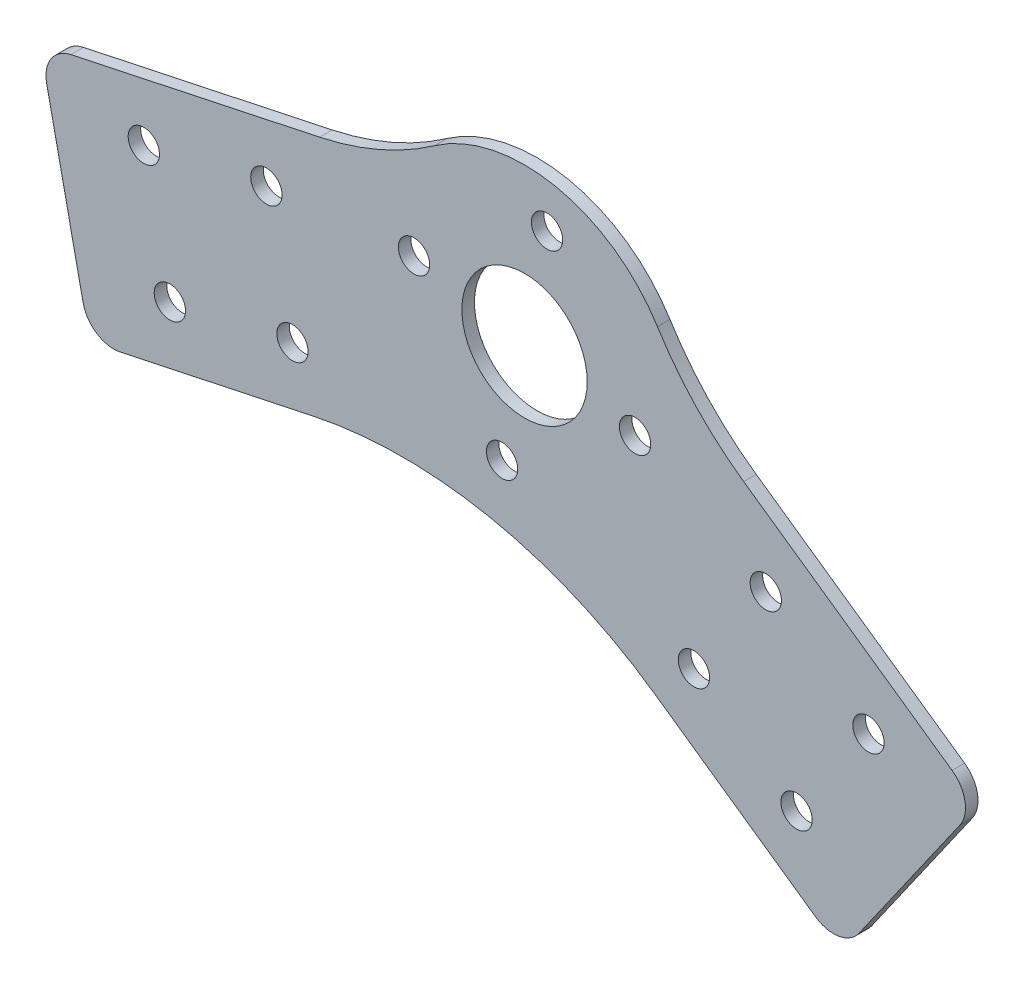
from build123d import *

# Parameters (mm, degrees)
SKETCH1_R           = 2.5
SKETCH1_R_2         = 10
BOSS_EXTRUDE1_DEPTH = 2
FILLET1_R           = 50
FILLET2_R           = 70
FILLET3_R           = 5


with BuildPart() as part:
    # Sketch1 → Boss-Extrude1 (new body)
    with BuildSketch(Plane.XY):
        with BuildLine():
            Line((-77.311392181, 2.991427603), (-69.410747929, -34.178181225))
            Line((-69.410747929, -34.178181225), (-4.13058082, -20.302453359))
            Line((-4.13058082, -20.302453359), (50.538451031, -58.582121568))
            Line((50.538451031, -58.582121568), (72.334355612, -27.454343885))
            Line((72.334355612, -27.454343885), (24.207597625, 6.244374848))
            ThreePointArc((24.207597625, 6.244374848), (4.98419836, 24.498117616), (-19.843339473, 15.206639292))
            Line((-19.843339473, 15.206639292), (-77.311392181, 2.991427603))
        make_face()
        with Locations((-60.767972952, -2.693225442)):
            Circle(SKETCH1_R, mode=Mode.SUBTRACT)
        with Locations((-56.609739136, -22.256177456)):
            Circle(SKETCH1_R, mode=Mode.SUBTRACT)
        with Locations((-37.046787121, -18.09794364)):
            Circle(SKETCH1_R, mode=Mode.SUBTRACT)
        with Locations((-41.205020938, 1.465008375)):
            Circle(SKETCH1_R, mode=Mode.SUBTRACT)
        with Locations((38.501846135, -14.751537011)):
            Circle(SKETCH1_R, mode=Mode.SUBTRACT)
        with Locations((27.030317408, -31.134577897)):
            Circle(SKETCH1_R, mode=Mode.SUBTRACT)
        with Locations((43.413358294, -42.606106624)):
            Circle(SKETCH1_R, mode=Mode.SUBTRACT)
        with Locations((54.884887021, -26.223065738)):
            Circle(SKETCH1_R, mode=Mode.SUBTRACT)
        Circle(SKETCH1_R_2, mode=Mode.SUBTRACT)
        with Locations((3.58862282, 17.638644683)):
            Circle(SKETCH1_R, mode=Mode.SUBTRACT)
        with Locations((17.638644683, -3.58862282)):
            Circle(SKETCH1_R, mode=Mode.SUBTRACT)
        with Locations((-3.58862282, -17.638644683)):
            Circle(SKETCH1_R, mode=Mode.SUBTRACT)
        with Locations((-17.638644683, 3.58862282)):
            Circle(SKETCH1_R, mode=Mode.SUBTRACT)
    extrude(amount=BOSS_EXTRUDE1_DEPTH)

    # Fillet1
    fillet1_edges = [part.edges().sort_by_distance(p)[0] for p in [
        (-19.843339473, 15.206639292, 1),
        (24.207597625, 6.244374848, 1),
    ]]
    fillet(fillet1_edges, radius=FILLET1_R)

    # Fillet2
    fillet2_edges = [part.edges().sort_by_distance(p)[0] for p in [
        (-4.13058082, -20.302453359, 1),
    ]]
    fillet(fillet2_edges, radius=FILLET2_R)

    # Fillet3
    fillet3_edges = [part.edges().sort_by_distance(p)[0] for p in [
        (72.334355612, -27.454343885, 1),
        (50.538451031, -58.582121568, 1),
        (-69.410747929, -34.178181225, 1),
        (-77.311392181, 2.991427603, 1),
    ]]
    fillet(fillet3_edges, radius=FILLET3_R)


solid = part.part
